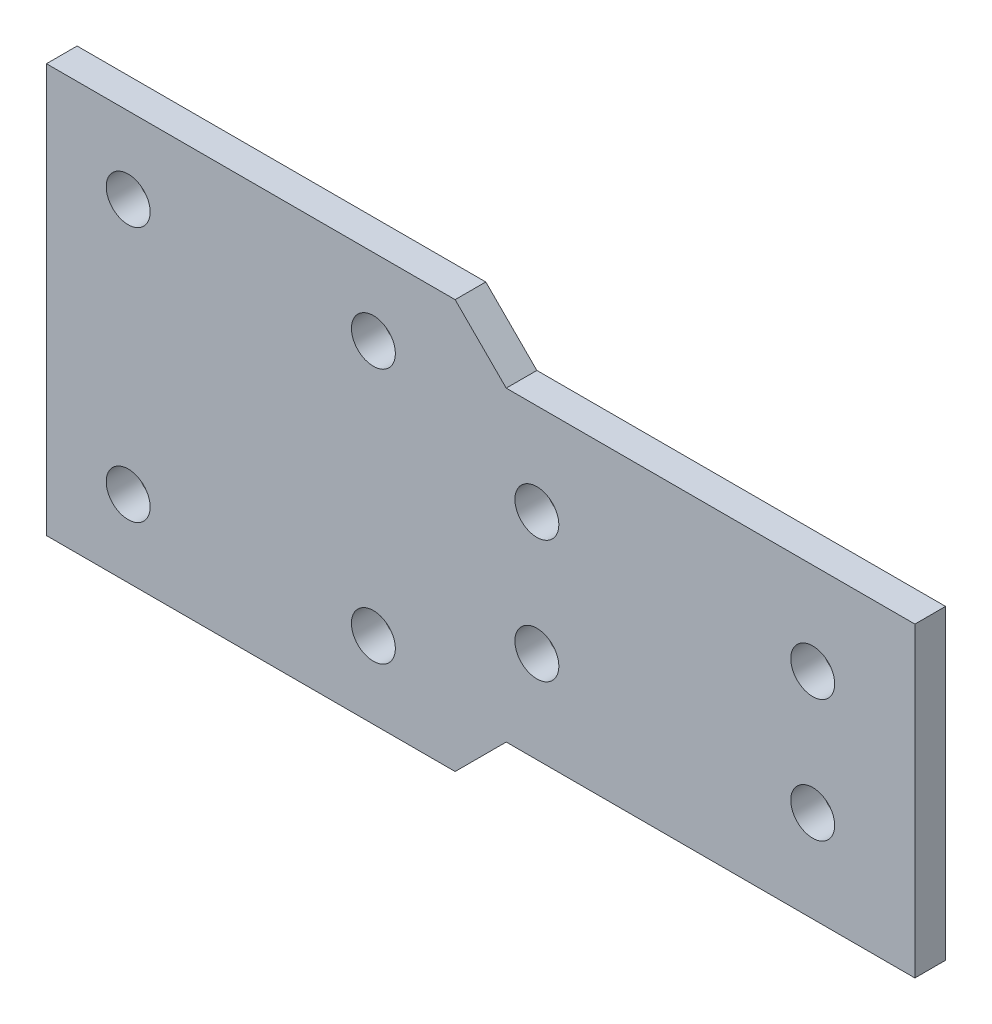
from build123d import *

# Parameters (mm, degrees)
SKETCH1_R      = 2.15
EXTRUDE1_DEPTH = 3


with BuildPart() as part:
    # Sketch1 → Extrude1 (new body)
    with BuildSketch(Plane.XY):
        Polygon((0, 20), (5, 15), (45, 15), (45, -15), (5, -15), (0, -20), (-40, -20), (-40, 20), align=None)
        with Locations((-32, 12.5)):
            Circle(SKETCH1_R, mode=Mode.SUBTRACT)
        with Locations((-8, 12.5)):
            Circle(SKETCH1_R, mode=Mode.SUBTRACT)
        with Locations((-32, -12.5)):
            Circle(SKETCH1_R, mode=Mode.SUBTRACT)
        with Locations((-8, -12.5)):
            Circle(SKETCH1_R, mode=Mode.SUBTRACT)
        with Locations((8, 6)):
            Circle(SKETCH1_R, mode=Mode.SUBTRACT)
        with Locations((8, -6)):
            Circle(SKETCH1_R, mode=Mode.SUBTRACT)
        with Locations((35, 6)):
            Circle(SKETCH1_R, mode=Mode.SUBTRACT)
        with Locations((35, -6)):
            Circle(SKETCH1_R, mode=Mode.SUBTRACT)
    extrude(amount=EXTRUDE1_DEPTH)


solid = part.part
